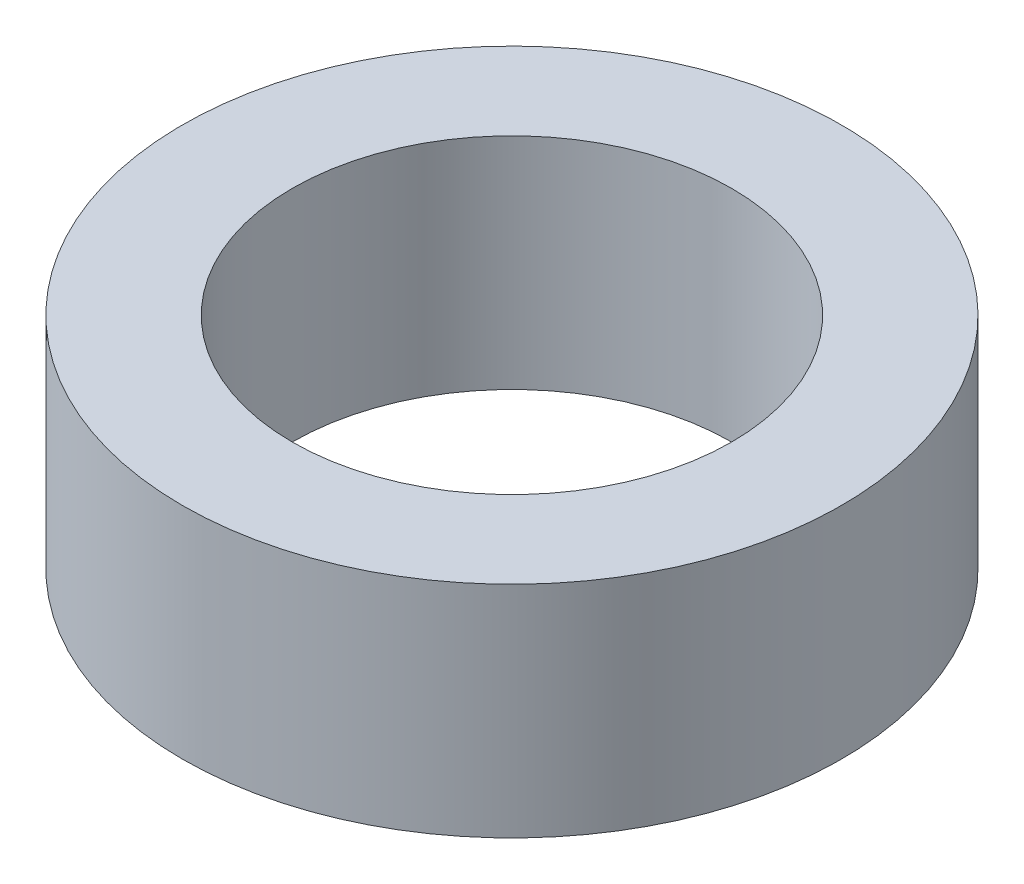
from build123d import *

# Parameters (mm, degrees)
SKETCH1_R           = 9.525
SKETCH1_R_2         = 6.35
BOSS_EXTRUDE1_DEPTH = 6.35


with BuildPart() as part:
    # Sketch1 → Boss-Extrude1 (new body)
    with BuildSketch(Plane(origin=(0, 0, 0), x_dir=(1, 0, 0), z_dir=(0, 1, 0))):
        Circle(SKETCH1_R)
        Circle(SKETCH1_R_2, mode=Mode.SUBTRACT)
    extrude(amount=BOSS_EXTRUDE1_DEPTH)


solid = part.part
